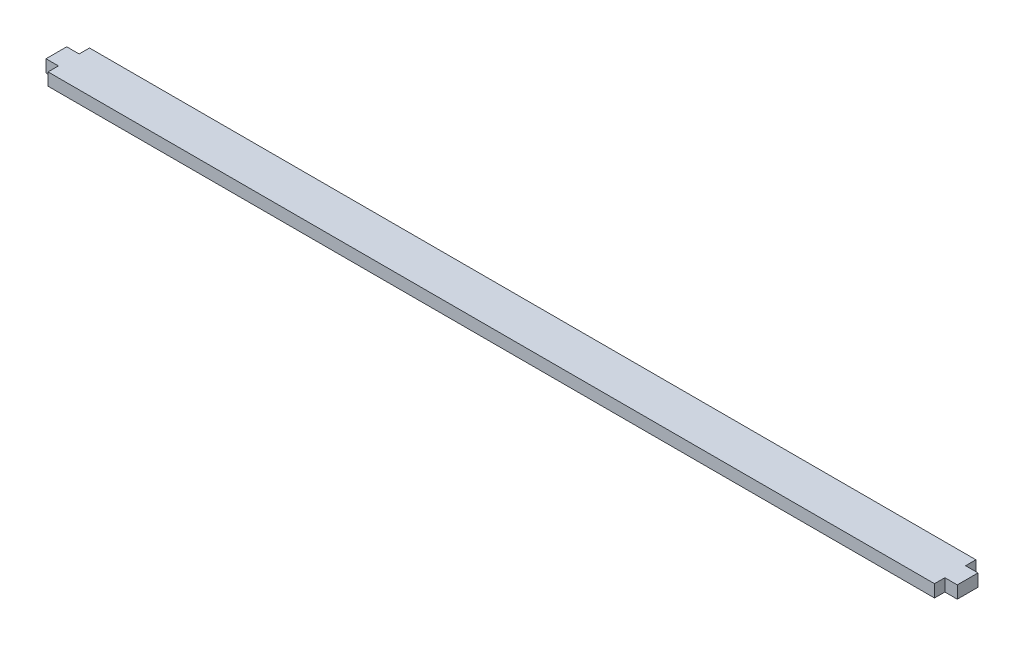
from build123d import *

# Parameters (mm, degrees)
CROQUIS1_W              = 3
CROQUIS1_H              = 5
CROQUIS1_W_2            = 214
CROQUIS1_H_2            = 10
SALIENTE_EXTRUIR1_DEPTH = 3


with BuildPart() as part:
    # Croquis1 → Saliente-Extruir1 (new body)
    with BuildSketch(Plane(origin=(0, 0, 0), x_dir=(1, 0, 0), z_dir=(0, 1, 0))):
        with Locations((108.5, 0)):
            Rectangle(CROQUIS1_W, CROQUIS1_H)
        Rectangle(CROQUIS1_W_2, CROQUIS1_H_2)
        with Locations((-108.5, 0)):
            Rectangle(CROQUIS1_W, CROQUIS1_H)
    extrude(amount=SALIENTE_EXTRUIR1_DEPTH)


solid = part.part
